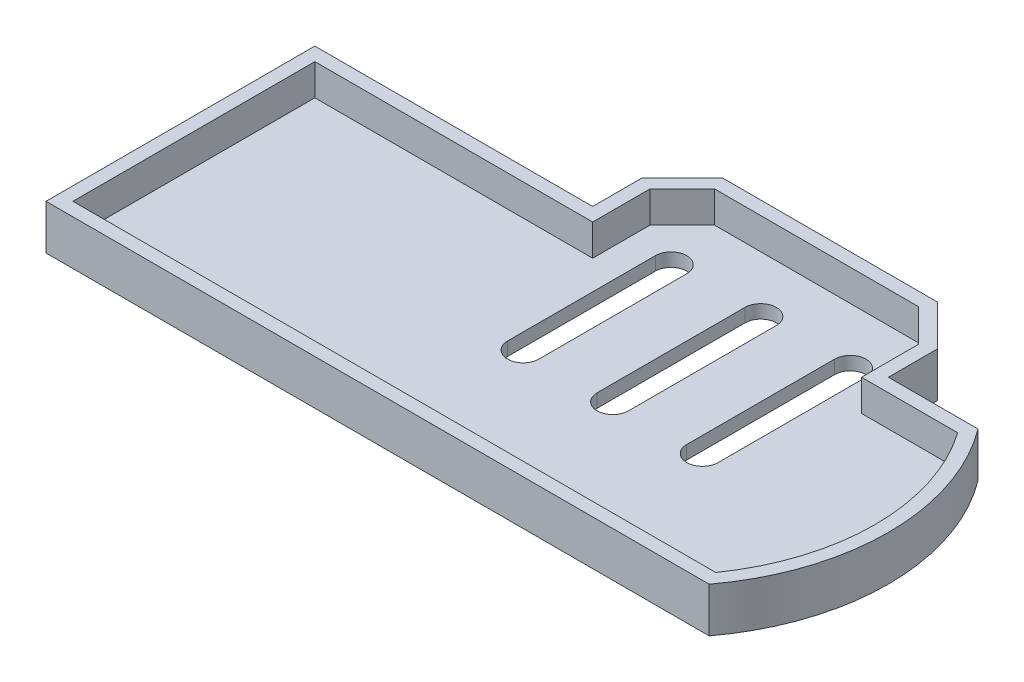
from build123d import *

# Parameters (mm, degrees)
EXTRUDE_1_DEPTH     = 10
CUT_EXTRUDE_1_DEPTH = 7


with BuildPart() as part:
    # Эскиз1 → Бобышка-Вытянуть1 (new body)
    with BuildSketch(Plane(origin=(0, 0, 0), x_dir=(1, 0, 0), z_dir=(0, 1, 0))):
        with BuildLine():
            Line((0, 0), (0, 60))
            Line((0, 60), (62, 60))
            Line((62, 60), (62, 71))
            Line((62, 71), (71, 80))
            Line((71, 80), (119, 80))
            Line((119, 80), (128, 71))
            Line((128, 71), (128, 60))
            Line((128, 60), (148, 60))
            ThreePointArc((148, 60), (158, 30), (148, 0))
            Line((148, 0), (0, 0))
        make_face()
        with BuildLine():
            Line((98.5, 64.5), (98.5, 31.5))
            ThreePointArc((98.5, 31.5), (95, 28), (91.5, 31.5))
            Line((91.5, 31.5), (91.5, 64.5))
            ThreePointArc((91.5, 64.5), (95, 68), (98.5, 64.5))
        make_face(mode=Mode.SUBTRACT)
        with BuildLine():
            Line((78.5, 64.5), (78.5, 31.5))
            ThreePointArc((78.5, 31.5), (75, 28), (71.5, 31.5))
            Line((71.5, 31.5), (71.5, 64.5))
            ThreePointArc((71.5, 64.5), (75, 68), (78.5, 64.5))
        make_face(mode=Mode.SUBTRACT)
        with BuildLine():
            Line((111.5, 64.5), (111.5, 31.5))
            ThreePointArc((111.5, 31.5), (115, 28), (118.5, 31.5))
            Line((118.5, 31.5), (118.5, 64.5))
            ThreePointArc((118.5, 64.5), (115, 68), (111.5, 64.5))
        make_face(mode=Mode.SUBTRACT)
    extrude(amount=EXTRUDE_1_DEPTH)

    # Эскиз3 → Вырез-Вытянуть1 (cut)
    with BuildSketch(Plane(origin=(0, 10, 0), x_dir=(1, 0, 0), z_dir=(0, 1, 0))):
        with BuildLine():
            Line((125, 57), (125, 69.757359313))
            Line((125, 69.757359313), (117.757359313, 77))
            Line((117.757359313, 77), (72.242640687, 77))
            Line((72.242640687, 77), (65, 69.757359313))
            Line((65, 69.757359313), (65, 57))
            Line((65, 57), (3, 57))
            Line((3, 57), (3, 3))
            Line((3, 3), (146.470768123, 3))
            ThreePointArc((146.470768123, 3), (155, 30), (146.470768123, 57))
            Line((146.470768123, 57), (125, 57))
        make_face()
    extrude(amount=-CUT_EXTRUDE_1_DEPTH, mode=Mode.SUBTRACT)


solid = part.part
